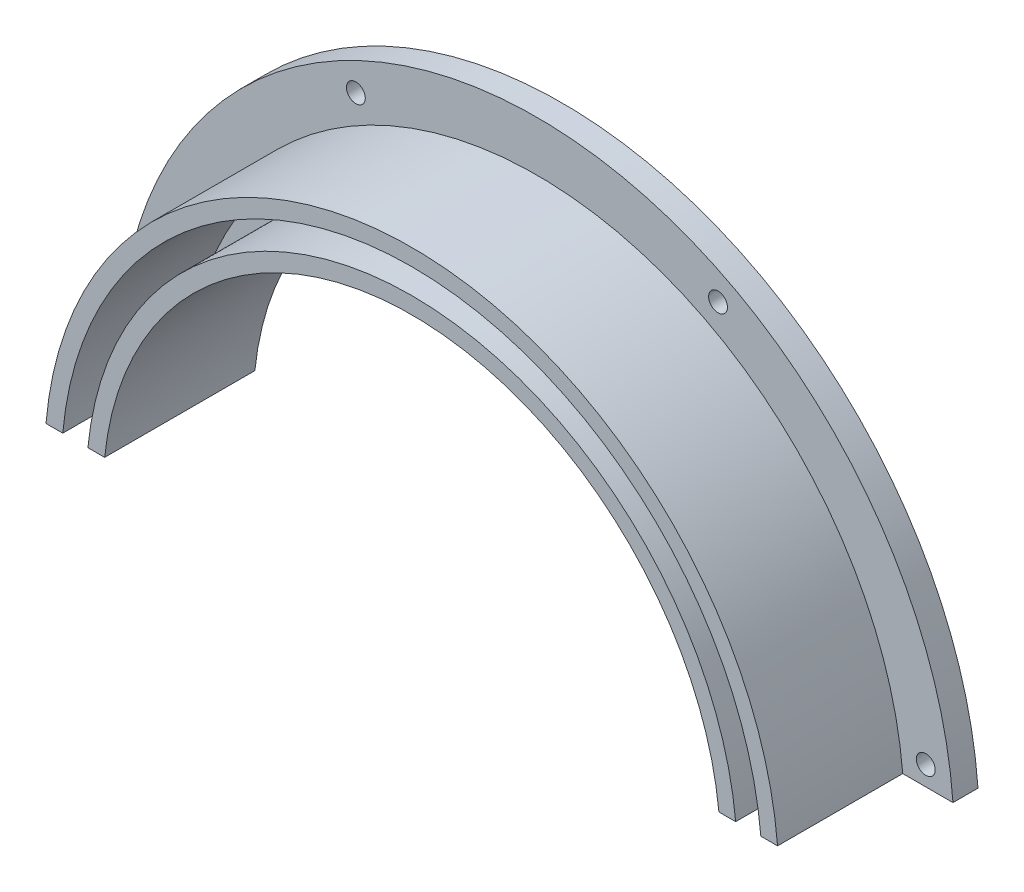
from build123d import *

# Parameters (mm, degrees)
REVOLVE1_ANGLE                  = 180
SKETCH2_W                       = 162.072956604
SKETCH2_H                       = 3.8
CUT_EXTRUDE1_DEPTH              = 19
F_4_40_TAPPED_HOLE1_D           = 2.2606
F_4_40_TAPPED_HOLE1_CSINK_D     = 4.1148
F_4_40_TAPPED_HOLE1_CSINK_ANGLE = 90
CIRPATTERN1_COUNT               = 4
CIRPATTERN1_ANGLE               = 165


with BuildPart() as part:
    # Sketch1 → Revolve1 (revolve, symmetric)
    with BuildSketch(Plane(origin=(0, 0, 0), x_dir=(0, 0, -1), z_dir=(1, 0, 0))) as revolve1_sk:
        Polygon((0, 37), (-18, 37), (-18, 39), (-3, 39), (-3, 42), (-18, 42), (-18, 44), (-3, 44), (-3, 50), (0, 50), align=None)
    revolve(axis=Axis((0, 0, 0), (0, 0, 1)), revolution_arc=REVOLVE1_ANGLE / 2)
    revolve(revolve1_sk.sketch, axis=Axis((0, 0, 0), (0, 0, -1)), revolution_arc=REVOLVE1_ANGLE / 2)

    # Sketch2 → Cut-Extrude1 (cut, through all)
    with BuildSketch(Plane(origin=(0, 0, 0), x_dir=(-1, 0, 0), z_dir=(0, 0, -1))):
        with Locations((0, 1.9)):
            Rectangle(SKETCH2_W, SKETCH2_H)
    extrude(amount=-CUT_EXTRUDE1_DEPTH, mode=Mode.SUBTRACT)

    # #4-40 Tapped Hole1 (through all)
    with Locations(Plane(origin=(0, 0, 0), x_dir=(-1, 0, 0), z_dir=(0, 0, -1))):
        with Locations((-46.597908485, 6.134731034)):
            f_4_40_tapped_hole1 = CounterSinkHole(F_4_40_TAPPED_HOLE1_D / 2, F_4_40_TAPPED_HOLE1_CSINK_D / 2, counter_sink_angle=F_4_40_TAPPED_HOLE1_CSINK_ANGLE)

    # CirPattern1: #4-40 Tapped Hole1 ×4 about axis
    cirpattern1_axis = Axis((0, 0, 0), (0, 0, 1))
    for i in range(1, CIRPATTERN1_COUNT):
        add(f_4_40_tapped_hole1.rotate(cirpattern1_axis, i * CIRPATTERN1_ANGLE / (CIRPATTERN1_COUNT - 1)), mode=Mode.SUBTRACT)


solid = part.part
